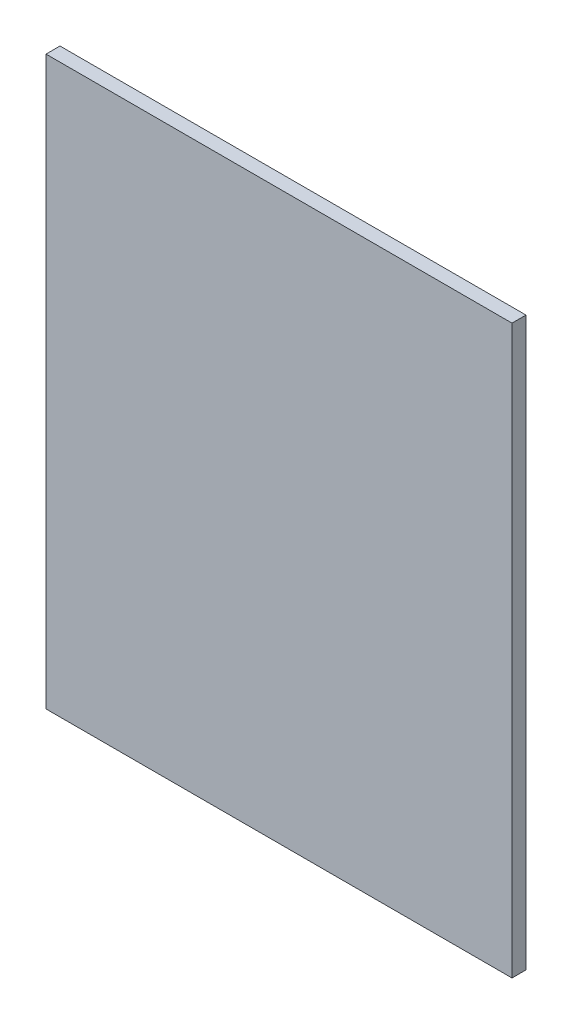
from build123d import *

# Parameters (mm, degrees)
SKETCH1_W           = 1115
SKETCH1_H           = 1357
BOSS_EXTRUDE1_DEPTH = 33.45


with BuildPart() as part:
    # Sketch1 → Boss-Extrude1 (new body)
    with BuildSketch(Plane.XY):
        Rectangle(SKETCH1_W, SKETCH1_H)
    extrude(amount=BOSS_EXTRUDE1_DEPTH)


solid = part.part
